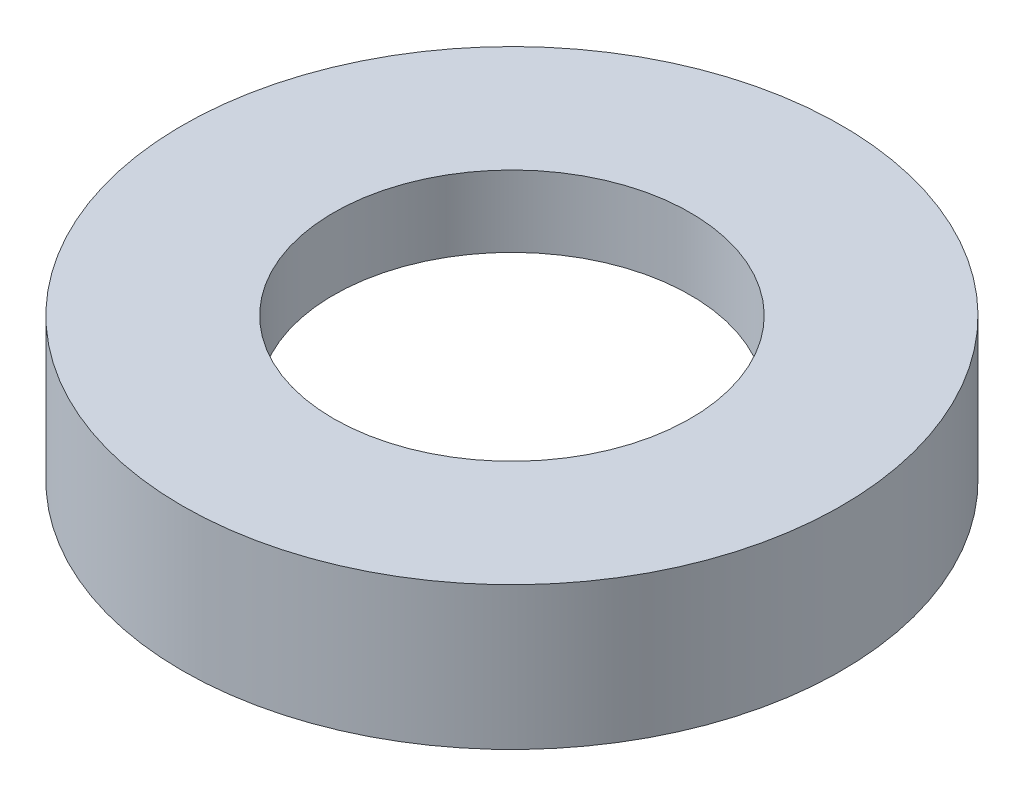
from build123d import *


with BuildPart() as part:
    # 草图1 → 旋转1 (revolve)
    with BuildSketch(Plane.XY, mode=Mode.PRIVATE) as revolve_1_sk:
        Polygon((23.5, 0), (23.5, 4.5), (24.1, 4.5), (24.1, 5.5), (13.75, 5.5), (13.75, 11), (25.4, 11), (25.4, 0), align=None)
    revolve(revolve_1_sk.sketch.rotate(Axis((0, 60.020820414, 0), (0, -1, 0)), 90), axis=Axis((0, 60.020820414, 0), (0, -1, 0)))  # turned: the seam where the file's is


solid = part.part
